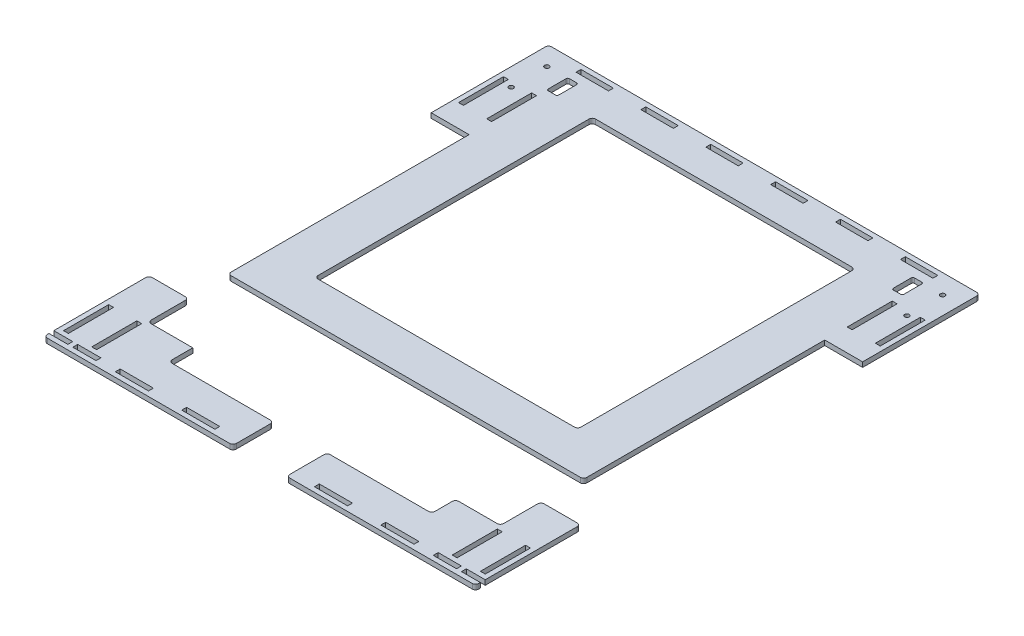
from build123d import *

# Parameters (mm, degrees)
SKETCH1_W               = 3
SKETCH1_H               = 27.8409
SKETCH1_W_2             = 20.4615
SKETCH1_H_2             = 3
SKETCH1_W_3             = 162
SKETCH1_H_3             = 261
SKETCH1_H_4             = 27.7273
SKETCH1_W_4             = 20
BOSS_EXTRUDE1_DEPTH     = 3
SKETCH4_W               = 162
SKETCH4_H               = 25
BOSS_EXTRUDE2_DEPTH     = 3
SKETCH3_W               = 28.65
SKETCH3_H               = 25.3182
SKETCH3_W_2             = 27.65
SKETCH3_H_2             = 25
SKETCH3_W_3             = 33
CUT_EXTRUDE2_DEPTH      = 1
CUT_EXTRUDE2_DEPTH_BACK = 4
FILLET1_R               = 2
FILLET2_R               = 2
FILLET3_R               = 2
SKETCH5_W               = 3
SKETCH5_H               = 3
BOSS_EXTRUDE3_DEPTH     = 3
SKETCH6_R               = 1.4
CUT_EXTRUDE3_DEPTH      = 1
CUT_EXTRUDE3_DEPTH_BACK = 4


with BuildPart() as part:
    # Sketch1 → Boss-Extrude1 (new body)
    with BuildSketch(Plane(origin=(0, 0, 0), x_dir=(1, 0, 0), z_dir=(0, 1, 0))):
        Polygon((-133, -152.5), (-133, -155.5), (133, -155.5), (133, -152.5), (112.4444, -152.5), (103.975, -152.5), (103.975, -149.5), (112.4444, -149.5), (133, -149.5), (133, -90.8182), (109.65, -90.8182), (109.65, 83.1818), (133, 83.1818), (133, 155.5), (-133, 155.5), (-133, 83.1818), (-109.65, 83.1818), (-109.65, -90.8182), (-133, -90.8182), (-133, -149.5), (-112.4444, -149.5), (-103.975, -149.5), (-103.975, -152.5), (-112.4444, -152.5), align=None)
        with Locations((-128.5, -132.57955)):
            Rectangle(SKETCH1_W, SKETCH1_H, mode=Mode.SUBTRACT)
        with Locations((-111.15, -132.57955)):
            Rectangle(SKETCH1_W, SKETCH1_H, mode=Mode.SUBTRACT)
        with Locations((-81.846, -151)):
            Rectangle(SKETCH1_W_2, SKETCH1_H_2, mode=Mode.SUBTRACT)
        with Locations((-40.923, -151)):
            Rectangle(SKETCH1_W_2, SKETCH1_H_2, mode=Mode.SUBTRACT)
        with Locations((0, -151)):
            Rectangle(SKETCH1_W_2, SKETCH1_H_2, mode=Mode.SUBTRACT)
        with Locations((40.923, -151)):
            Rectangle(SKETCH1_W_2, SKETCH1_H_2, mode=Mode.SUBTRACT)
        with Locations((81.846, -151)):
            Rectangle(SKETCH1_W_2, SKETCH1_H_2, mode=Mode.SUBTRACT)
        with Locations((111.15, -132.57955)):
            Rectangle(SKETCH1_W, SKETCH1_H, mode=Mode.SUBTRACT)
        with Locations((128.5, -132.57955)):
            Rectangle(SKETCH1_W, SKETCH1_H, mode=Mode.SUBTRACT)
        Rectangle(SKETCH1_W_3, SKETCH1_H_3, mode=Mode.SUBTRACT)
        with Locations((-128.5, 110.90905)):
            Rectangle(SKETCH1_W, SKETCH1_H_4, mode=Mode.SUBTRACT)
        with Locations((-111.15, 110.90905)):
            Rectangle(SKETCH1_W, SKETCH1_H_4, mode=Mode.SUBTRACT)
        with Locations((-100, 151)):
            Rectangle(SKETCH1_W_4, SKETCH1_H_2, mode=Mode.SUBTRACT)
        with Locations((-60, 151)):
            Rectangle(SKETCH1_W_4, SKETCH1_H_2, mode=Mode.SUBTRACT)
        with Locations((-20, 151)):
            Rectangle(SKETCH1_W_4, SKETCH1_H_2, mode=Mode.SUBTRACT)
        with Locations((20, 151)):
            Rectangle(SKETCH1_W_4, SKETCH1_H_2, mode=Mode.SUBTRACT)
        with Locations((60, 151)):
            Rectangle(SKETCH1_W_4, SKETCH1_H_2, mode=Mode.SUBTRACT)
        with Locations((111.15, 110.90905)):
            Rectangle(SKETCH1_W, SKETCH1_H_4, mode=Mode.SUBTRACT)
        with Locations((128.5, 110.90905)):
            Rectangle(SKETCH1_W, SKETCH1_H_4, mode=Mode.SUBTRACT)
        with Locations((100, 151)):
            Rectangle(SKETCH1_W_4, SKETCH1_H_2, mode=Mode.SUBTRACT)
    extrude(amount=BOSS_EXTRUDE1_DEPTH)

    # Sketch4 → Boss-Extrude2 (add)
    with BuildSketch(Plane.XZ):
        with Locations((0, 53)):
            Rectangle(SKETCH4_W, SKETCH4_H)
    extrude(amount=-BOSS_EXTRUDE2_DEPTH)

    # Sketch3 → Cut-Extrude2 (cut, two sides)
    with BuildSketch(Plane(origin=(0, 3, 0), x_dir=(1, 0, 0), z_dir=(0, 1, 0))) as cut_extrude2_sk:
        with Locations((-95.325, -78.1591)):
            Rectangle(SKETCH3_W, SKETCH3_H)
        with Locations((-94.825, -103.3182)):
            Rectangle(SKETCH3_W_2, SKETCH3_H_2)
        with Locations((0, -143)):
            Rectangle(SKETCH3_W_3, SKETCH3_H_2)
        with Locations((94.825, -103.3182)):
            Rectangle(SKETCH3_W_2, SKETCH3_H_2)
        with Locations((95.325, -78.1591)):
            Rectangle(SKETCH3_W, SKETCH3_H)
    extrude(amount=CUT_EXTRUDE2_DEPTH, mode=Mode.SUBTRACT)
    extrude(cut_extrude2_sk.sketch, amount=-CUT_EXTRUDE2_DEPTH_BACK, mode=Mode.SUBTRACT)

    # Fillet1
    fillet1_edges = [part.edges().sort_by_distance(p)[0] for p in [
        (-81, 1.5, -130.5),
        (81, 1.5, -130.5),
        (81, 1.5, 40.5),
        (-81, 1.5, 40.5),
        (133, 1.5, -155.5),
        (-109.65, 1.5, 65.5),
        (109.65, 1.5, 65.5),
        (-133, 1.5, -155.5),
    ]]
    fillet(fillet1_edges, radius=FILLET1_R)

    # Fillet2
    fillet2_edges = [part.edges().sort_by_distance(p)[0] for p in [
        (-108.65, 1.5, 115.8182),
        (-108.65, 1.5, 90.8182),
        (-16.5, 1.5, 155.5),
        (-133, 1.5, 155.5),
        (-81, 1.5, 130.5),
        (-133, 1.5, 90.8182),
        (-16.5, 1.5, 130.5),
    ]]
    fillet(fillet2_edges, radius=FILLET2_R)

    # Fillet3
    fillet3_edges = [part.edges().sort_by_distance(p)[0] for p in [
        (81, 1.5, 130.5),
        (133, 1.5, 90.8182),
        (133, 1.5, 155.5),
        (16.5, 1.5, 155.5),
        (16.5, 1.5, 130.5),
        (81, 1.5, 115.8182),
        (108.65, 1.5, 90.8182),
        (108.65, 1.5, 115.8182),
    ]]
    fillet(fillet3_edges, radius=FILLET3_R)

    # Sketch5 → Boss-Extrude3 (add)
    with BuildSketch(Plane(origin=(0, 0, 0), x_dir=(1, 0, 0), z_dir=(0, 1, 0))):
        with Locations((-119.825, -151)):
            Rectangle(SKETCH5_W, SKETCH5_H)
        with Locations((119.825, -151)):
            Rectangle(SKETCH5_W, SKETCH5_H)
    extrude(amount=BOSS_EXTRUDE3_DEPTH)

    # Sketch6 → Cut-Extrude3 (cut, two sides)
    with BuildSketch(Plane(origin=(0, 3, 0), x_dir=(1, 0, 0), z_dir=(0, 1, 0))) as cut_extrude3_sk:
        with Locations((-122, 143.5)):
            Circle(SKETCH6_R)
        with Locations((-122, 121.5)):
            Circle(SKETCH6_R)
        with Locations((122, 121.5)):
            Circle(SKETCH6_R)
        with Locations((122, 143.5)):
            Circle(SKETCH6_R)
        with BuildLine():
            Line((-104.15, 131), (-108.65, 131))
            ThreePointArc((-108.65, 131), (-109.357106781, 131.292893219), (-109.65, 132))
            Line((-109.65, 132), (-109.65, 143))
            ThreePointArc((-109.65, 143), (-109.357106781, 143.707106781), (-108.65, 144))
            Line((-108.65, 144), (-104.15, 144))
            ThreePointArc((-104.15, 144), (-103.442893219, 143.707106781), (-103.15, 143))
            Line((-103.15, 143), (-103.15, 132))
            ThreePointArc((-103.15, 132), (-103.442893219, 131.292893219), (-104.15, 131))
        make_face()
        with BuildLine():
            Line((104.15, 144), (108.65, 144))
            ThreePointArc((108.65, 144), (109.357106781, 143.707106781), (109.65, 143))
            Line((109.65, 143), (109.65, 132))
            ThreePointArc((109.65, 132), (109.357106781, 131.292893219), (108.65, 131))
            Line((108.65, 131), (104.15, 131))
            ThreePointArc((104.15, 131), (103.442893219, 131.292893219), (103.15, 132))
            Line((103.15, 132), (103.15, 143))
            ThreePointArc((103.15, 143), (103.442893219, 143.707106781), (104.15, 144))
        make_face()
    extrude(amount=CUT_EXTRUDE3_DEPTH, mode=Mode.SUBTRACT)
    extrude(cut_extrude3_sk.sketch, amount=-CUT_EXTRUDE3_DEPTH_BACK, mode=Mode.SUBTRACT)


solid = part.part
